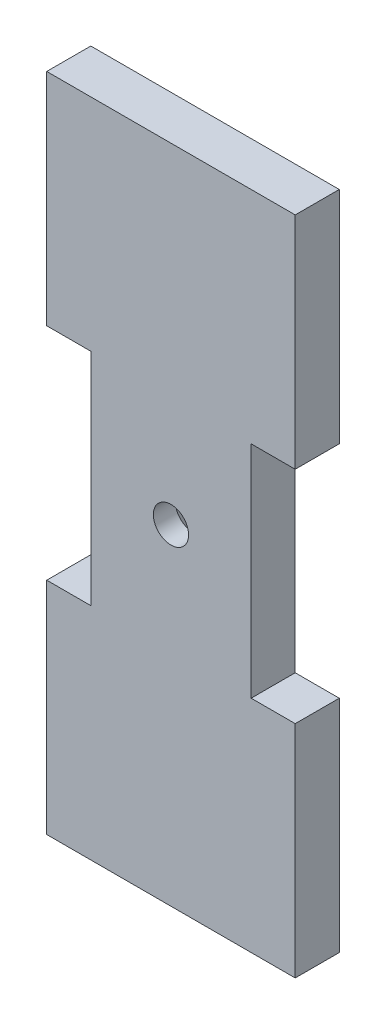
from build123d import *

# Parameters (mm, degrees)
SKETCH1_R           = 4
BOSS_EXTRUDE1_DEPTH = 10
CHAMFER1_SIZE       = 5


with BuildPart() as part:
    # Sketch1 → Boss-Extrude1 (new body)
    with BuildSketch(Plane.XY):
        Polygon((0, 150), (56.4, 150), (56.4, 100), (46.4, 100), (46.4, 50), (56.4, 50), (56.4, 0), (0, 0), (0, 50), (10, 50), (10, 100), (0, 100), align=None)
        with Locations((28.2, 75)):
            Circle(SKETCH1_R, mode=Mode.SUBTRACT)
    extrude(amount=BOSS_EXTRUDE1_DEPTH)

    # Chamfer1
    chamfer1_edges = [part.edges().sort_by_distance(p)[0] for p in [
        (24.2, 75, 0),
    ]]
    chamfer(chamfer1_edges, length=CHAMFER1_SIZE)


solid = part.part
